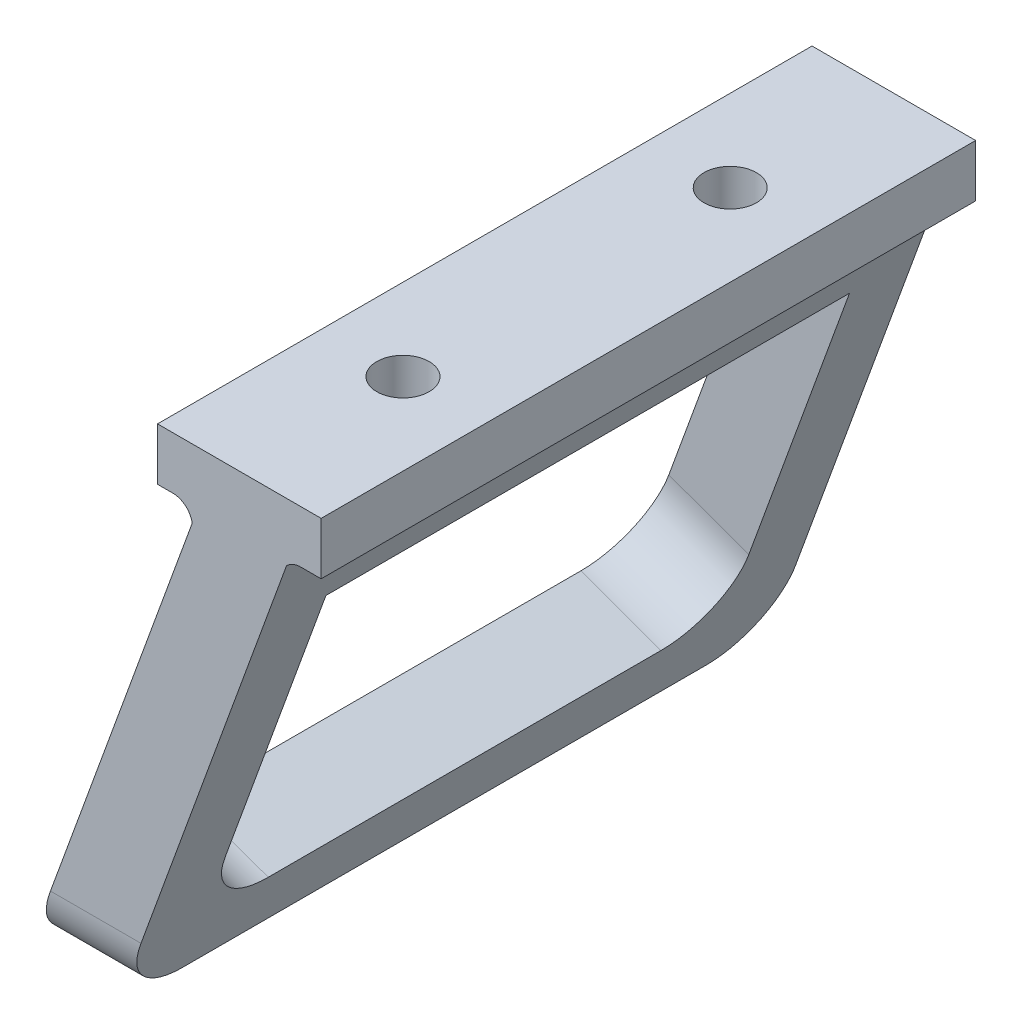
from build123d import *

# Parameters (mm, degrees)
BOSS_EXTRUDE1_DEPTH       = 50
BOSS_EXTRUDE1_DEPTH_BACK  = 50
FILLET1_R                 = 10
CUT_EXTRUDE2_DEPTH        = 50
F_1_0MM_DOWEL_HOLE1_D     = 8
F_1_0MM_DOWEL_HOLE1_DEPTH = 15
F_1_0MM_DOWEL_HOLE1_TIP   = 2.403442476


with BuildPart() as part:
    # Sketch1 → Boss-Extrude1 (new, two sides: drawn at the far end of the back side and taken through both)
    with BuildSketch(Plane.XY.offset(-BOSS_EXTRUDE1_DEPTH_BACK)):
        with BuildLine():
            Line((-12.5, 8), (12.5, 8))
            Line((12.5, 8), (12.5, 0))
            Line((12.5, 0), (9.375807417, 0))
            ThreePointArc((9.375807417, 0), (8.191786524, -0.243535865), (7.2, -0.93460365))
            Line((7.2, -0.93460365), (-18.665688958, -72))
            Line((-18.665688958, -72), (-32.5, -72))
            Line((-32.5, -72), (-7.2, -2.488821288))
            ThreePointArc((-7.2, -2.488821288), (-8.223971278, -0.705055977), (-10.156128604, 0))
            Line((-10.156128604, 0), (-12.5, 0))
            Line((-12.5, 0), (-12.5, 8))
        make_face()
    extrude(amount=BOSS_EXTRUDE1_DEPTH + BOSS_EXTRUDE1_DEPTH_BACK)

    # Fillet1
    fillet1_edges = [part.edges().sort_by_distance(p)[0] for p in [
        (-25.582844479, -72, -50),
        (-25.582844479, -72, 50),
    ]]
    fillet(fillet1_edges, radius=FILLET1_R)

    # Sketch2 → Cut-Extrude2 (cut)
    with BuildSketch(Plane(origin=(-5.557868252, 2.02289861, 0), x_dir=(0, 0, 1), z_dir=(-0.9396926207859081, 0.3420201433256699, 0))):
        with BuildLine():
            Line((-40, -10.029869223), (40, -10.029869223))
            Line((40, -10.029869223), (40, -55.029869223))
            ThreePointArc((40, -55.029869223), (37.071067812, -62.100937034), (30, -65.029869223))
            Line((30, -65.029869223), (-30, -65.029869223))
            ThreePointArc((-30, -65.029869223), (-37.071067812, -62.100937034), (-40, -55.029869223))
            Line((-40, -55.029869223), (-40, -10.029869223))
        make_face()
    extrude(amount=-CUT_EXTRUDE2_DEPTH, mode=Mode.SUBTRACT)

    # Ø1.0mm Dowel Hole1
    with Locations(Plane(origin=(0, 8, 0), x_dir=(1, 0, 0), z_dir=(0, 1, 0))):
        with Locations((0, 25), (0, -25)):
            Hole(F_1_0MM_DOWEL_HOLE1_D / 2, depth=F_1_0MM_DOWEL_HOLE1_DEPTH)
            with Locations((0, 0, -(F_1_0MM_DOWEL_HOLE1_DEPTH + F_1_0MM_DOWEL_HOLE1_TIP / 2))):  # 118° drill point
                Cone(0, F_1_0MM_DOWEL_HOLE1_D / 2, F_1_0MM_DOWEL_HOLE1_TIP, mode=Mode.SUBTRACT)


solid = part.part
